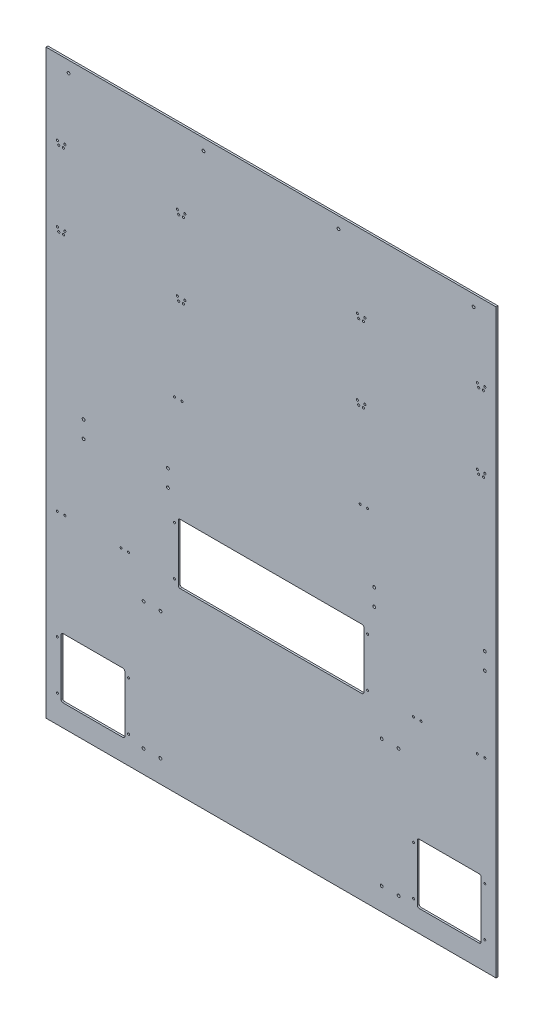
from build123d import *

# Parameters (mm, degrees)
SKETCH1_W               = 1524
SKETCH1_H               = 1968.5
BOSS_EXTRUDE1_DEPTH     = 6.35
SKETCH2_W               = 628.65
SKETCH2_H               = 203.2
CUT_EXTRUDE1_DEPTH      = 7.35
FILLET1_R               = 6.35
SKETCH3_W               = 215.9
SKETCH3_H               = 203.2
CUT_EXTRUDE2_DEPTH      = 7.35
SKETCH4_W               = 215.9
SKETCH4_H               = 203.2
CUT_EXTRUDE3_DEPTH      = 6.35
FILLET2_R               = 6.35
SKETCH5_R               = 3.571875
CUT_EXTRUDE4_DEPTH      = 7.35
LPATTERN1_COUNT         = 2
LPATTERN1_PITCH         = 406.4
LPATTERN1_COUNT_DIR2    = 2
LPATTERN1_PITCH_DIR2    = 254
MIRROR1_COPY_1_SKETCH_R = 3.571875
MIRROR1_COPY_1_DEPTH    = 7.35
MIRROR1_COPY_2_SKETCH_R = 3.571875
MIRROR1_COPY_2_DEPTH    = 7.35
MIRROR1_COPY_3_SKETCH_R = 3.571875
MIRROR1_COPY_3_DEPTH    = 7.35
SKETCH6_R               = 4.7625
CUT_EXTRUDE5_DEPTH      = 7.35
LPATTERN2_COUNT         = 4
LPATTERN2_PITCH         = 457.2
SKETCH7_R               = 3.3655
CUT_EXTRUDE6_DEPTH      = 7.35
SKETCH8_R               = 4.7625
CUT_EXTRUDE7_DEPTH      = 7.35
SKETCH10_R              = 4.7625
CUT_EXTRUDE8_DEPTH      = 7.35


with BuildPart() as part:
    # Sketch1 → Boss-Extrude1 (new body)
    with BuildSketch(Plane.XY):
        Rectangle(SKETCH1_W, SKETCH1_H)
    extrude(amount=BOSS_EXTRUDE1_DEPTH)

    # Sketch2 → Cut-Extrude1 (cut, through all)
    with BuildSketch(Plane.XY.offset(6.35)):
        with Locations((0, -275.4122)):
            Rectangle(SKETCH2_W, SKETCH2_H)
    extrude(amount=-CUT_EXTRUDE1_DEPTH, mode=Mode.SUBTRACT)

    # Fillet1
    fillet1_edges = [part.edges().sort_by_distance(p)[0] for p in [
        (314.325, -173.8122, 3.175),
        (314.325, -377.0122, 3.175),
        (-314.325, -377.0122, 3.175),
        (-314.325, -173.8122, 3.175),
    ]]
    fillet(fillet1_edges, radius=FILLET1_R)

    # Sketch3 → Cut-Extrude2 (cut, through all)
    with BuildSketch(Plane.XY.offset(6.35)):
        with Locations((-603.25, -808.8122)):
            Rectangle(SKETCH3_W, SKETCH3_H)
    extrude(amount=-CUT_EXTRUDE2_DEPTH, mode=Mode.SUBTRACT)

    # Sketch4 → Cut-Extrude3 (cut)
    with BuildSketch(Plane.XY.offset(6.35)):
        with Locations((603.25, -808.8122)):
            Rectangle(SKETCH4_W, SKETCH4_H)
    extrude(amount=-CUT_EXTRUDE3_DEPTH, mode=Mode.SUBTRACT)

    # Fillet2
    fillet2_edges = [part.edges().sort_by_distance(p)[0] for p in [
        (711.2, -707.2122, 3.175),
        (711.2, -910.4122, 3.175),
        (495.3, -910.4122, 3.175),
        (495.3, -707.2122, 3.175),
        (-495.3, -707.2122, 3.175),
        (-495.3, -910.4122, 3.175),
        (-711.2, -910.4122, 3.175),
        (-711.2, -707.2122, 3.175),
    ]]
    fillet(fillet2_edges, radius=FILLET2_R)

    # Sketch5 → Cut-Extrude4 (cut, through all)
    with BuildSketch(Plane.XY.offset(6.35)):
        with Locations((-723.9, 730.25)):
            Circle(SKETCH5_R)
        with Locations((-698.5, 730.25)):
            Circle(SKETCH5_R)
        with Locations((-719.1375, 717.55)):
            Circle(SKETCH5_R)
        with Locations((-703.2625, 717.55)):
            Circle(SKETCH5_R)
    cut_extrude4 = extrude(amount=-CUT_EXTRUDE4_DEPTH, mode=Mode.SUBTRACT)

    # LPattern1: Cut-Extrude4 2 × 2
    with Locations(*[(i * LPATTERN1_PITCH, -j * LPATTERN1_PITCH_DIR2, 0) for i in range(LPATTERN1_COUNT) for j in range(LPATTERN1_COUNT_DIR2) if (i, j) != (0, 0)]):
        add(cut_extrude4, mode=Mode.SUBTRACT)

    # Mirror1: Cut-Extrude4 across plane
    add(cut_extrude4.mirror(Plane(origin=(0, 0, 0), x_dir=(0, 0, 1), z_dir=(1, 0, 0))), mode=Mode.SUBTRACT)

    # Mirror1 copy 1 sketch → Mirror1 copy 1 (cut, through all)
    with BuildSketch(Plane(origin=(0, -254, 6.35), x_dir=(-1, 0, 0), z_dir=(0, 0, 1))):
        with Locations((-723.9, -730.25)):
            Circle(MIRROR1_COPY_1_SKETCH_R)
        with Locations((-698.5, -730.25)):
            Circle(MIRROR1_COPY_1_SKETCH_R)
        with Locations((-719.1375, -717.55)):
            Circle(MIRROR1_COPY_1_SKETCH_R)
        with Locations((-703.2625, -717.55)):
            Circle(MIRROR1_COPY_1_SKETCH_R)
    extrude(amount=-MIRROR1_COPY_1_DEPTH, mode=Mode.SUBTRACT)

    # Mirror1 copy 2 sketch → Mirror1 copy 2 (cut, through all)
    with BuildSketch(Plane(origin=(-406.4, 0, 6.35), x_dir=(-1, 0, 0), z_dir=(0, 0, 1))):
        with Locations((-723.9, -730.25)):
            Circle(MIRROR1_COPY_2_SKETCH_R)
        with Locations((-698.5, -730.25)):
            Circle(MIRROR1_COPY_2_SKETCH_R)
        with Locations((-719.1375, -717.55)):
            Circle(MIRROR1_COPY_2_SKETCH_R)
        with Locations((-703.2625, -717.55)):
            Circle(MIRROR1_COPY_2_SKETCH_R)
    extrude(amount=-MIRROR1_COPY_2_DEPTH, mode=Mode.SUBTRACT)

    # Mirror1 copy 3 sketch → Mirror1 copy 3 (cut, through all)
    with BuildSketch(Plane(origin=(-406.4, -254, 6.35), x_dir=(-1, 0, 0), z_dir=(0, 0, 1))):
        with Locations((-723.9, -730.25)):
            Circle(MIRROR1_COPY_3_SKETCH_R)
        with Locations((-698.5, -730.25)):
            Circle(MIRROR1_COPY_3_SKETCH_R)
        with Locations((-719.1375, -717.55)):
            Circle(MIRROR1_COPY_3_SKETCH_R)
        with Locations((-703.2625, -717.55)):
            Circle(MIRROR1_COPY_3_SKETCH_R)
    extrude(amount=-MIRROR1_COPY_3_DEPTH, mode=Mode.SUBTRACT)

    # Sketch6 → Cut-Extrude5 (cut, through all)
    with BuildSketch(Plane.XY.offset(6.35)):
        with Locations((-685.8, 946.15)):
            Circle(SKETCH6_R)
    cut_extrude5 = extrude(amount=-CUT_EXTRUDE5_DEPTH, mode=Mode.SUBTRACT)

    # LPattern2: Cut-Extrude5 ×4
    with Locations(*[(i * LPATTERN2_PITCH, 0, 0) for i in range(1, LPATTERN2_COUNT)]):
        add(cut_extrude5, mode=Mode.SUBTRACT)

    # Sketch7 → Cut-Extrude6 (cut, through all)
    with BuildSketch(Plane.XY.offset(6.35)):
        with Locations((-723.9, -726.2622)):
            Circle(SKETCH7_R)
        with Locations((-723.9, -891.3622)):
            Circle(SKETCH7_R)
        with Locations((-482.6, -726.2622)):
            Circle(SKETCH7_R)
        with Locations((-482.6, -891.3622)):
            Circle(SKETCH7_R)
        with Locations((482.6, -726.2622)):
            Circle(SKETCH7_R)
        with Locations((482.6, -891.3622)):
            Circle(SKETCH7_R)
        with Locations((723.9, -891.3622)):
            Circle(SKETCH7_R)
        with Locations((723.9, -726.2622)):
            Circle(SKETCH7_R)
        with Locations((-327.025, -192.8622)):
            Circle(SKETCH7_R)
        with Locations((-327.025, -357.9622)):
            Circle(SKETCH7_R)
        with Locations((327.025, -192.8622)):
            Circle(SKETCH7_R)
        with Locations((327.025, -357.9622)):
            Circle(SKETCH7_R)
        with Locations((-723.9, -357.9622)):
            Circle(SKETCH7_R)
        with Locations((-698.5, -357.9622)):
            Circle(SKETCH7_R)
        with Locations((-508, -357.9622)):
            Circle(SKETCH7_R)
        with Locations((-482.6, -357.9622)):
            Circle(SKETCH7_R)
        with Locations((482.6, -357.9622)):
            Circle(SKETCH7_R)
        with Locations((508, -357.9622)):
            Circle(SKETCH7_R)
        with Locations((698.5, -357.9622)):
            Circle(SKETCH7_R)
        with Locations((723.9, -357.9622)):
            Circle(SKETCH7_R)
        with Locations((-327.025, 175.4378)):
            Circle(SKETCH7_R)
        with Locations((-301.625, 175.4378)):
            Circle(SKETCH7_R)
        with Locations((301.625, 175.4378)):
            Circle(SKETCH7_R)
        with Locations((327.025, 175.4378)):
            Circle(SKETCH7_R)
    extrude(amount=-CUT_EXTRUDE6_DEPTH, mode=Mode.SUBTRACT)

    # Sketch8 → Cut-Extrude7 (cut, through all)
    with BuildSketch(Plane.XY.offset(6.35)):
        with Locations((349.25, -44.45)):
            Circle(SKETCH8_R)
        with Locations((349.25, -101.6)):
            Circle(SKETCH8_R)
        with Locations((374.65, -908.05)):
            Circle(SKETCH8_R)
        with Locations((431.8, -908.05)):
            Circle(SKETCH8_R)
        with Locations((374.65, -476.25)):
            Circle(SKETCH8_R)
        with Locations((431.8, -476.25)):
            Circle(SKETCH8_R)
    cut_extrude7 = extrude(amount=-CUT_EXTRUDE7_DEPTH, mode=Mode.SUBTRACT)

    # Mirror2: Cut-Extrude7 across plane
    add(cut_extrude7.mirror(Plane(origin=(0, 0, 0), x_dir=(0, 0, 1), z_dir=(1, 0, 0))), mode=Mode.SUBTRACT)

    # Sketch10 → Cut-Extrude8 (cut, through all)
    with BuildSketch(Plane.XY.offset(6.35)):
        with Locations((-635, -44.45)):
            Circle(SKETCH10_R)
        with Locations((-635, -101.6)):
            Circle(SKETCH10_R)
        with Locations((723.9, -44.45)):
            Circle(SKETCH10_R)
        with Locations((723.9, -101.6)):
            Circle(SKETCH10_R)
    extrude(amount=-CUT_EXTRUDE8_DEPTH, mode=Mode.SUBTRACT)


solid = part.part
